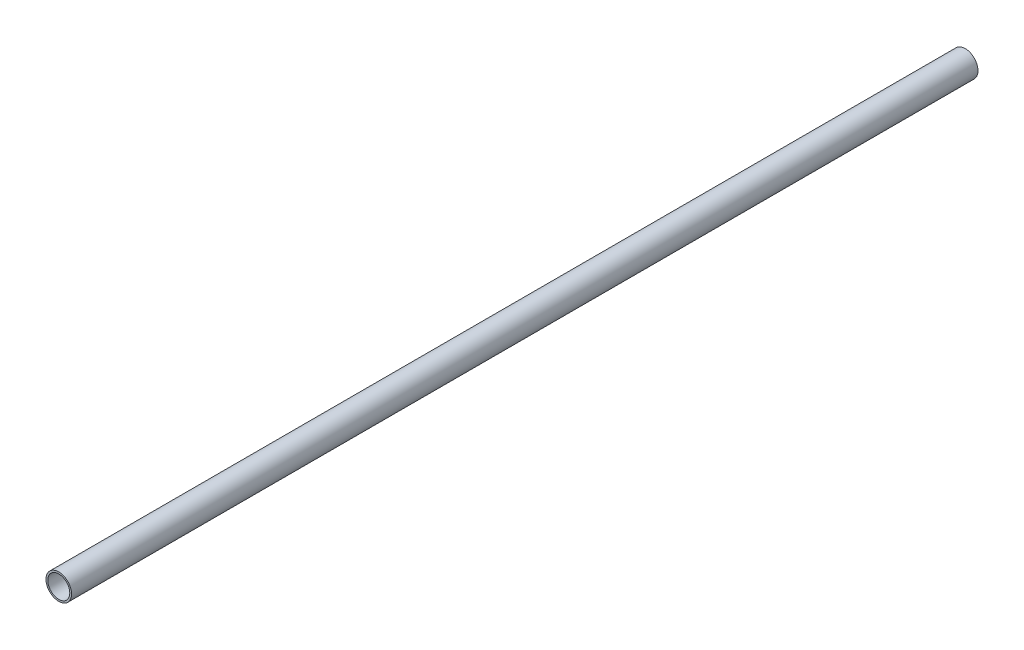
from build123d import *

# Parameters (mm, degrees)
SKETCH1_R           = 6.35
SKETCH1_R_2         = 5.461
BOSS_EXTRUDE1_DEPTH = 450


with BuildPart() as part:
    # Sketch1 → Boss-Extrude1 (new body)
    with BuildSketch(Plane.XY):
        Circle(SKETCH1_R)
        Circle(SKETCH1_R_2, mode=Mode.SUBTRACT)
    extrude(amount=BOSS_EXTRUDE1_DEPTH)


solid = part.part
